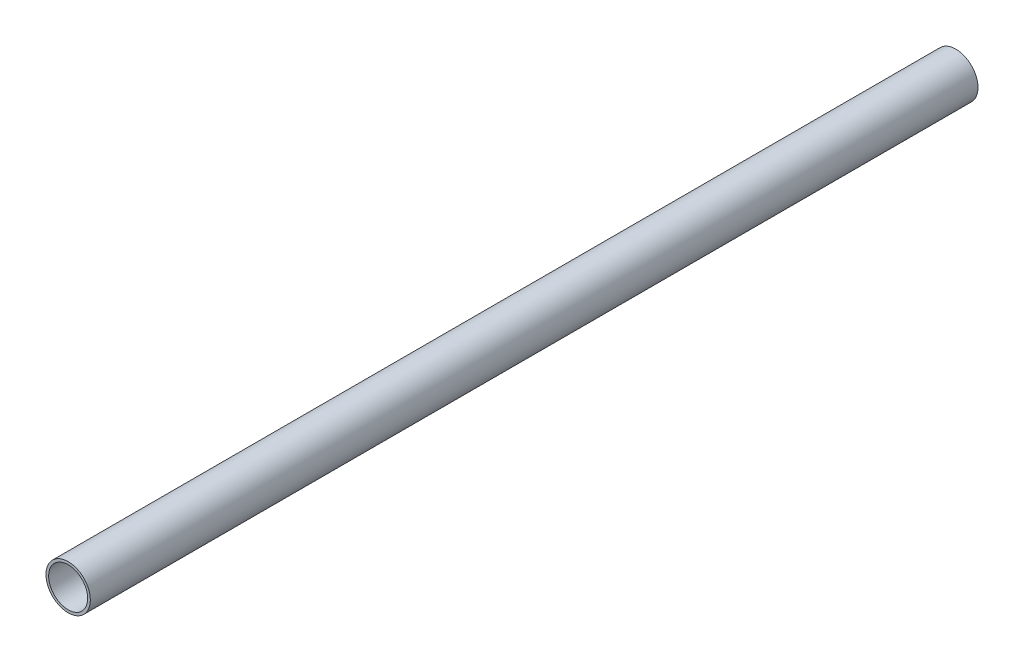
from build123d import *

# Parameters (mm, degrees)
ESQUISSE1_R        = 25
ESQUISSE1_R_2      = 22
BOSS_EXTRU_1_DEPTH = 1000


with BuildPart() as part:
    # Esquisse1 → Boss.-Extru.1 (new body)
    with BuildSketch(Plane.XY):
        Circle(ESQUISSE1_R)
        Circle(ESQUISSE1_R_2, mode=Mode.SUBTRACT)
    extrude(amount=BOSS_EXTRU_1_DEPTH)


solid = part.part
